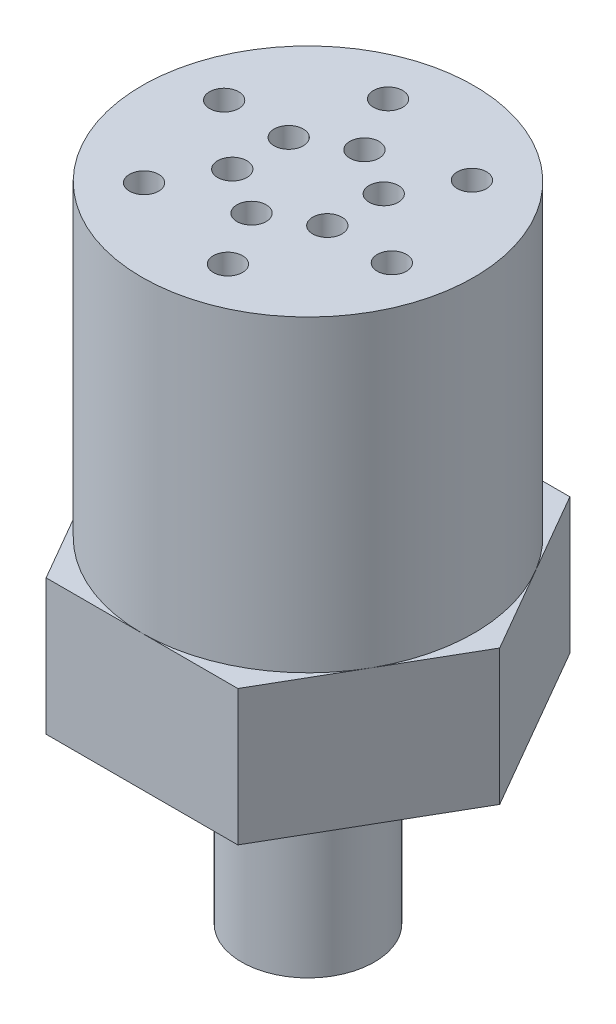
from build123d import *

# Parameters (mm, degrees)
SKETCH1_R                  = 15.875
NEOPRENE_BODY_DEPTH        = 29.464
ALUMINUM_BRONZE_BODY_DEPTH = 12.954
SKETCH3_R                  = 6.35
F_1_2_20_UNF_2A_DEPTH      = 19.05
SKETCH4_R                  = 1.397
CUT_EXTRUDE1_DEPTH         = 10.16


with BuildPart() as part:
    # Sketch1 → Neoprene Body (new body)
    with BuildSketch(Plane(origin=(0, 0, 0), x_dir=(1, 0, 0), z_dir=(0, 1, 0))):
        Circle(SKETCH1_R)
    extrude(amount=NEOPRENE_BODY_DEPTH)

    # Sketch4 → Cut-Extrude1 (cut)
    with BuildSketch(Plane(origin=(0, 29.464, 0), x_dir=(1, 0, 0), z_dir=(0, 1, 0))):
        with Locations((10.745000968, -2.725436897)):
            Circle(SKETCH4_R)
        with Locations((4.571512411, -2.725436897)):
            Circle(SKETCH4_R)
        with Locations((3.012202894, -10.668162251)):
            Circle(SKETCH4_R)
        with Locations((-0.074541384, -5.321764331)):
            Circle(SKETCH4_R)
        with Locations((-7.732798074, -7.942725353)):
            Circle(SKETCH4_R)
        with Locations((-4.646053795, -2.596327433)):
            Circle(SKETCH4_R)
        with Locations((-10.745000968, 2.725436897)):
            Circle(SKETCH4_R)
        with Locations((-4.571512411, 2.725436897)):
            Circle(SKETCH4_R)
        with Locations((-3.012202894, 10.668162251)):
            Circle(SKETCH4_R)
        with Locations((0.074541384, 5.321764331)):
            Circle(SKETCH4_R)
        with Locations((7.732798074, 7.942725353)):
            Circle(SKETCH4_R)
        with Locations((4.646053795, 2.596327433)):
            Circle(SKETCH4_R)
    extrude(amount=-CUT_EXTRUDE1_DEPTH, mode=Mode.SUBTRACT)


with BuildPart() as body_2:
    # Sketch2 → Aluminum Bronze Body (new body)
    with BuildSketch(Plane.XZ):
        Polygon((-9.165435523, 15.875), (9.165435523, 15.875), (18.330871047, 0), (9.165435523, -15.875), (-9.165435523, -15.875), (-18.330871047, 0), align=None)
    extrude(amount=ALUMINUM_BRONZE_BODY_DEPTH)


with BuildPart() as body_3:
    # Sketch3 → 1_2-20 UNF 2A (new body)
    with BuildSketch(Plane(origin=(0, -12.954, 0), x_dir=(-1, 0, 0), z_dir=(0, -1, 0))):
        Circle(SKETCH3_R)
    extrude(amount=F_1_2_20_UNF_2A_DEPTH)


solid = Compound([part.part, body_2.part, body_3.part])
